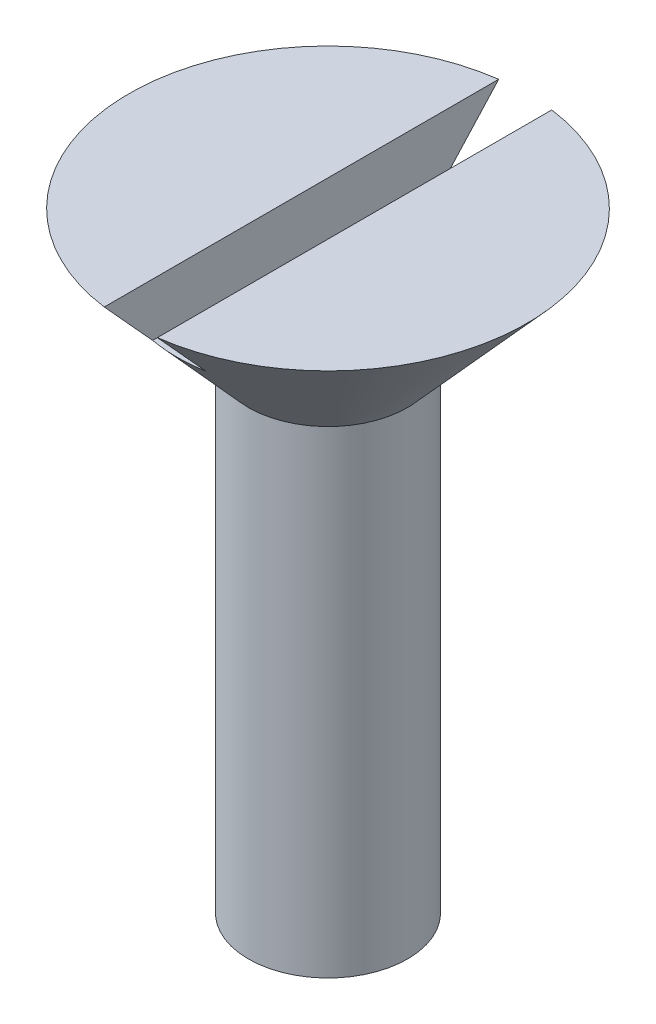
from build123d import *

# Parameters (mm, degrees)
SKETCH2_W               = 2
SKETCH2_H               = 4
CUT_EXTRUDE1_DEPTH      = 8.5
CUT_EXTRUDE1_DEPTH_BACK = 8.5


with BuildPart() as part:
    # Sketch1 → Revolve1 (revolve)
    with BuildSketch(Plane.XY):
        Polygon((0, 0), (3, 1.732050808), (3, 19.732050808), (7.5, 24.732050808), (0, 24.732050808), align=None)
    revolve(axis=Axis((0, 24.732050808, 0), (0, -1, 0)))

    # Sketch2 → Cut-Extrude1 (cut, two sides)
    with BuildSketch(Plane.XY) as cut_extrude1_sk:
        with Locations((0, 24.732050808)):
            Rectangle(SKETCH2_W, SKETCH2_H)
    extrude(amount=CUT_EXTRUDE1_DEPTH, mode=Mode.SUBTRACT)
    extrude(cut_extrude1_sk.sketch, amount=-CUT_EXTRUDE1_DEPTH_BACK, mode=Mode.SUBTRACT)


solid = part.part
